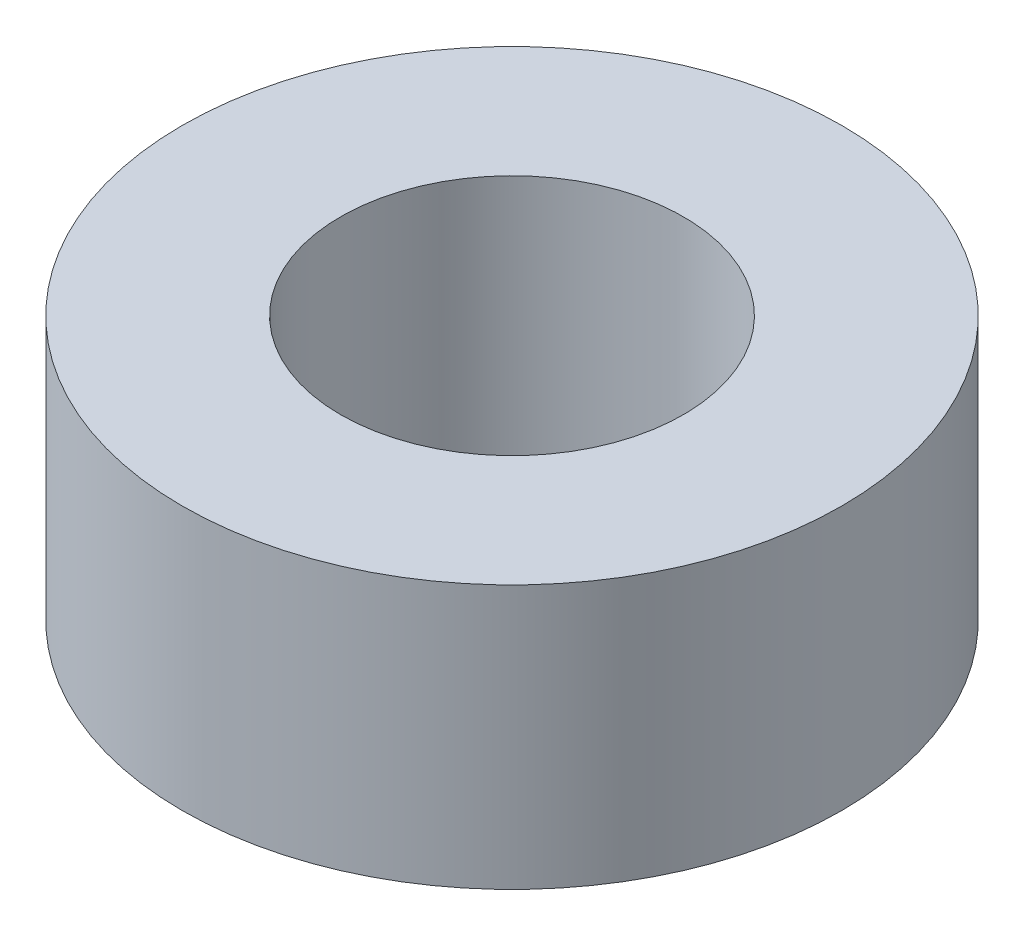
from build123d import *

# Parameters (mm, degrees)
SKETCH1_R           = 6.35
SKETCH1_R_2         = 3.302
BOSS_EXTRUDE1_DEPTH = 5.08


with BuildPart() as part:
    # Sketch1 → Boss-Extrude1 (new body)
    with BuildSketch(Plane(origin=(0, 0, 0), x_dir=(1, 0, 0), z_dir=(0, 1, 0))):
        Circle(SKETCH1_R)
        Circle(SKETCH1_R_2, mode=Mode.SUBTRACT)
    extrude(amount=BOSS_EXTRUDE1_DEPTH)


solid = part.part
